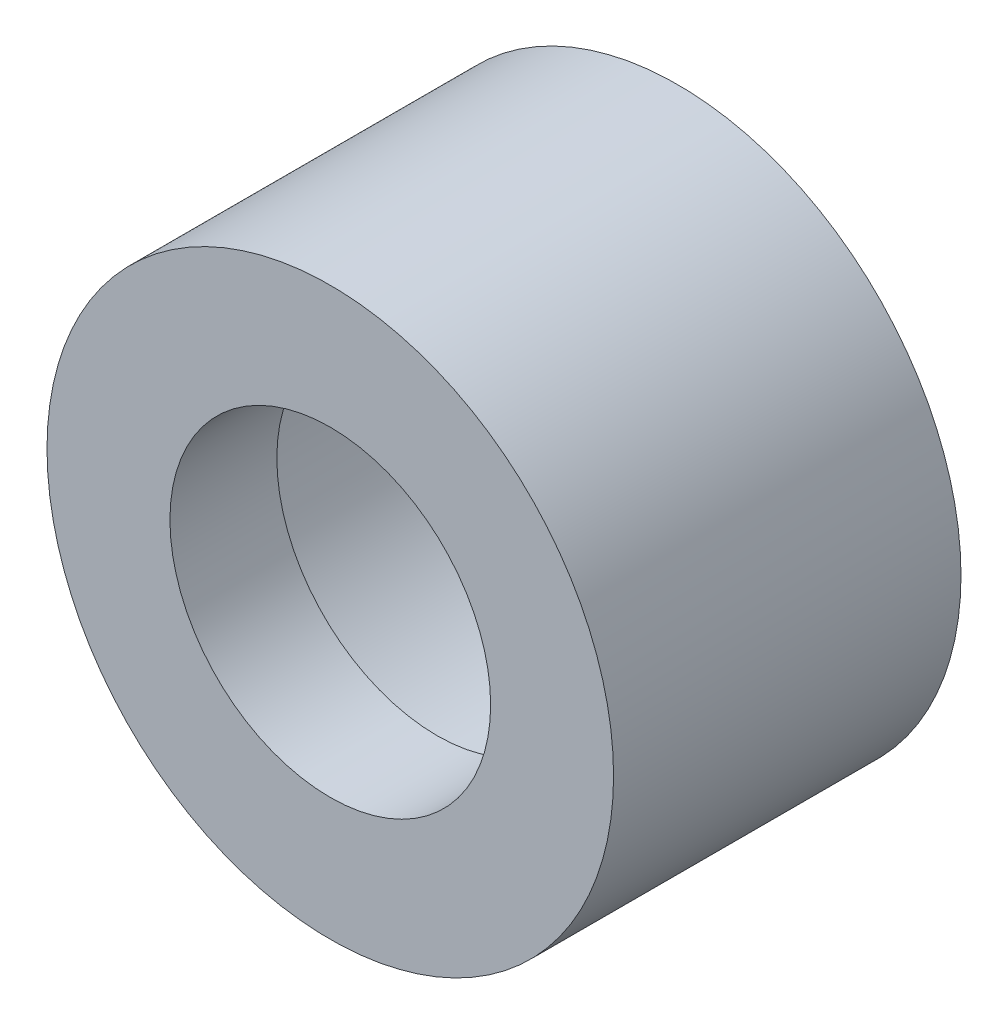
from build123d import *

# Parameters (mm, degrees)
SKETCH1_R           = 13.462
BOSS_EXTRUDE3_DEPTH = 16.51
SKETCH1_15_R        = 7.62
CUT_EXTRUDE3_DEPTH  = 16.51
SKETCH1_16_R        = 10.414
SKETCH1_16_R_2      = 7.62
CUT_EXTRUDE4_DEPTH  = 11.43


with BuildPart() as part:
    # Sketch1 → Boss-Extrude3 (new body)
    with BuildSketch(Plane.XY):
        Circle(SKETCH1_R)
    extrude(amount=BOSS_EXTRUDE3_DEPTH)

    # Sketch1_15 → Cut-Extrude3 (cut)
    with BuildSketch(Plane.XY):
        Circle(SKETCH1_15_R)
    extrude(amount=CUT_EXTRUDE3_DEPTH, mode=Mode.SUBTRACT)

    # Sketch1_16 → Cut-Extrude4 (cut)
    with BuildSketch(Plane.XY):
        Circle(SKETCH1_16_R)
        Circle(SKETCH1_16_R_2, mode=Mode.SUBTRACT)
    extrude(amount=CUT_EXTRUDE4_DEPTH, mode=Mode.SUBTRACT)


solid = part.part
